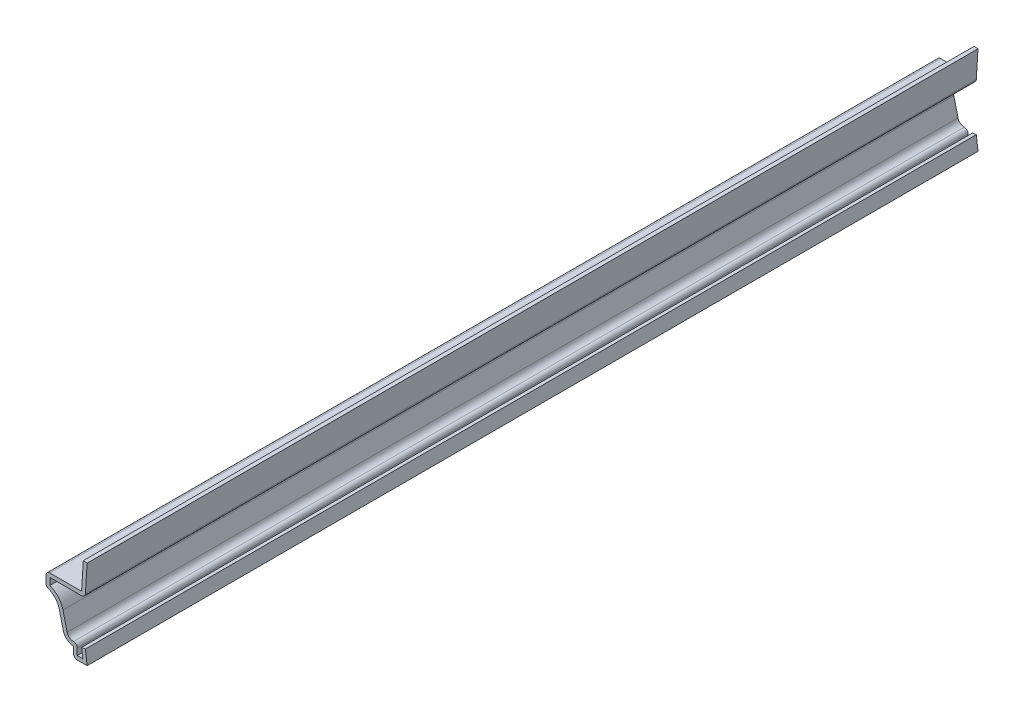
from build123d import *

# Parameters (mm, degrees)
EXTRUDE_THIN1_DEPTH = 206.375
FILLET1_R           = 0.889


with BuildPart() as part:
    # Sketch1 → Extrude-Thin1 (new body)
    with BuildSketch(Plane.XY):
        with BuildLine():
            Line((-0.887268742, 20.6375), (-1.284143742, 14.2875))
            Line((-1.284143742, 14.2875), (-9.525, 14.2875))
            Line((-9.525, 14.2875), (-9.525, 11.1125))
            ThreePointArc((-9.525, 11.1125), (-7.568526944, 10.085272082), (-6.464654688, 8.170996748))
            Line((-6.464654688, 8.170996748), (-5.487457187, 4.194262971))
            ThreePointArc((-5.487457187, 4.194262971), (-4.644223798, 2.888538156), (-3.175, 2.38125))
            Line((-3.175, 2.38125), (-3.175, 0))
            Line((-3.175, 0), (0, 0))
            Line((0, 0), (-0.396875, 3.150097655))
            Line((-0.396875, 3.150097655), (-1.278902343, 3.038972655))
            Line((-1.278902343, 3.038972655), (-1.00803125, 0.889))
            Line((-1.00803125, 0.889), (-2.286, 0.889))
            Line((-2.286, 0.889), (-2.286, 3.563963783))
            ThreePointArc((-2.286, 3.563963783), (-3.680831863, 3.358596802), (-4.624139837, 4.406404795))
            Line((-4.624139837, 4.406404795), (-5.601337339, 8.383138572))
            ThreePointArc((-5.601337339, 8.383138572), (-6.695664903, 10.45982586), (-8.636, 11.780917313))
            Line((-8.636, 11.780917313), (-8.636, 13.3985))
            Line((-8.636, 13.3985), (-0.448971606, 13.3985))
            Line((-0.448971606, 13.3985), (0, 20.582045704))
            Line((0, 20.582045704), (-0.887268742, 20.6375))
        make_face()
    extrude(amount=-EXTRUDE_THIN1_DEPTH)

    # Fillet1
    fillet1_edges = [part.edges().sort_by_distance(p)[0] for p in [
        (-3.175, 0, -103.1875),
        (-9.525, 11.1125, -103.1875),
        (-9.525, 14.2875, -103.1875),
        (-0.448971606, 13.3985, -103.1875),
        (-2.286, 3.563963783, -103.1875),
    ]]
    fillet(fillet1_edges, radius=FILLET1_R)


solid = part.part
